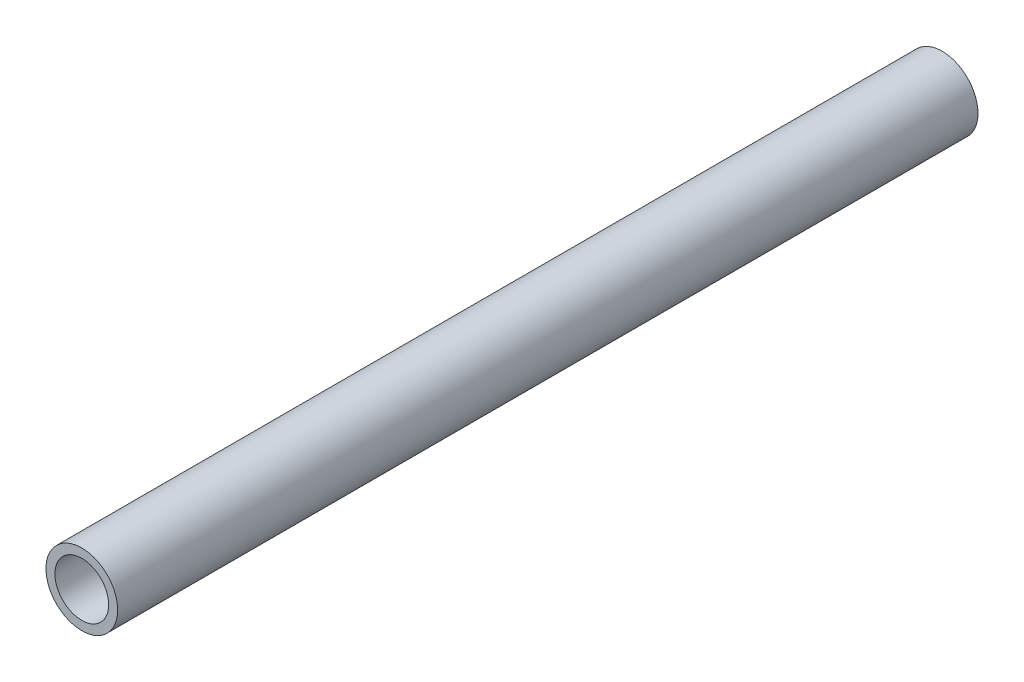
from build123d import *

# Parameters (mm, degrees)
SKETCH1_R           = 6.35
SKETCH1_R_2         = 4.7625
BOSS_EXTRUDE1_DEPTH = 76.2


with BuildPart() as part:
    # Sketch1 → Boss-Extrude1 (new body, symmetric)
    with BuildSketch(Plane.XY):
        Circle(SKETCH1_R)
        Circle(SKETCH1_R_2, mode=Mode.SUBTRACT)
    extrude(amount=BOSS_EXTRUDE1_DEPTH, both=True)


solid = part.part
